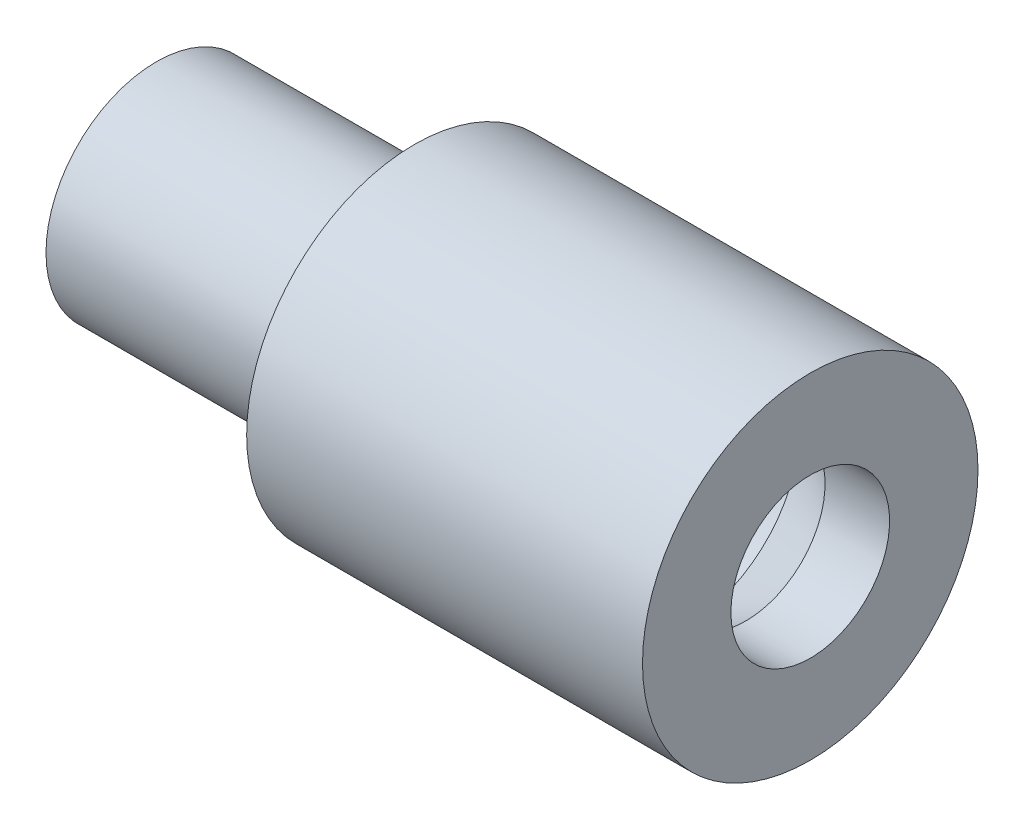
from build123d import *

# Parameters (mm, degrees)
SKETCH3_W = 10
SKETCH3_H = 1.2


with BuildPart() as part:
    # Sketch1 → Revolve1 (revolve)
    with BuildSketch(Plane(origin=(0, 0, 0), x_dir=(1, 0, 0), z_dir=(0, 1, 0))):
        Polygon((-5, 4.425), (-5, 6.5), (0, 6.5), (0, 5.3), (-2, 5.3), (-4, 4.425), align=None)
        Polygon((0, 5.15), (-1.934375, 5.15), (-3.934375, 4.275), (-5, 4.275), (-5, 3.075), (0, 3.075), align=None)
    revolve1 = revolve(axis=Axis((0, 0, 0), (1, 0, 0)))

    # Mirror1: Revolve1 across plane
    add(revolve1.mirror(Plane(origin=(0, 0, 0), x_dir=(0, 0, 1), z_dir=(1, 0, 0))))

    # Sketch2 → Revolve2 (revolve)
    with BuildSketch(Plane(origin=(0, 0, 0), x_dir=(1, 0, 0), z_dir=(0, 1, 0))):
        Polygon((10.33826859, 6.5), (5, 6.5), (5, 4.425), (5.5, 4.425), (7.83826859, 3.075), (10.33826859, 3.075), align=None)
    revolve(axis=Axis((0, 0, 0), (1, 0, 0)))

    # Sketch3 → Revolve3 (revolve)
    with BuildSketch(Plane(origin=(0, 0, 0), x_dir=(1, 0, 0), z_dir=(0, 1, 0))):
        with Locations((-10, 3.675)):
            Rectangle(SKETCH3_W, SKETCH3_H)
    revolve(axis=Axis((0, 0, 0), (-1, 0, 0)))


solid = part.part
